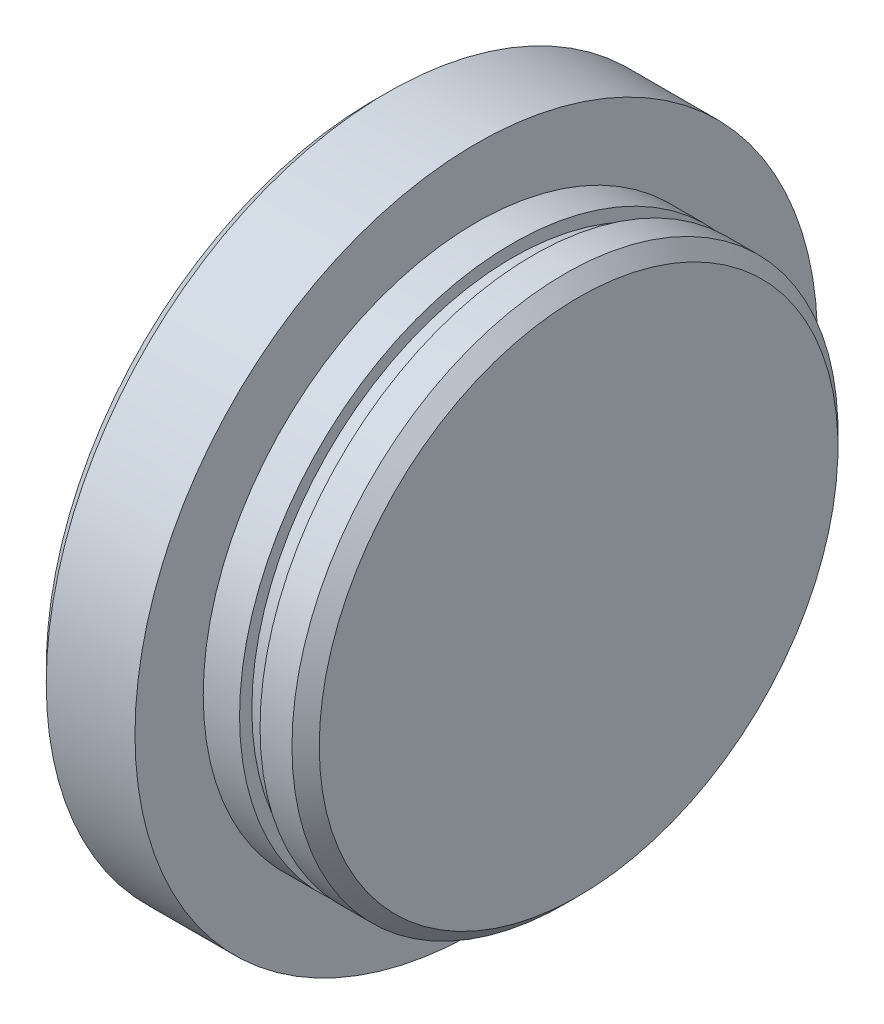
from build123d import *

# Parameters (mm, degrees)
FASE1_SIZE = 2


with BuildPart() as part:
    # Skizze1 → Rotation1 (revolve)
    with BuildSketch(Plane.XY):
        Polygon((0, 0), (0, 50), (15, 50), (15, 40), (20.322114174, 40), (20.322114174, 38.2), (23.322114174, 38.2), (23.322114174, 40), (30, 40), (30, 0), align=None)
    revolve(axis=Axis((0, 0, 0), (1, 0, 0)))

    # Fase1
    fase1_edges = [part.edges().sort_by_distance(p)[0] for p in [
        (0, -50, 0),
        (30, -40, 0),
    ]]
    chamfer(fase1_edges, length=FASE1_SIZE)


solid = part.part
